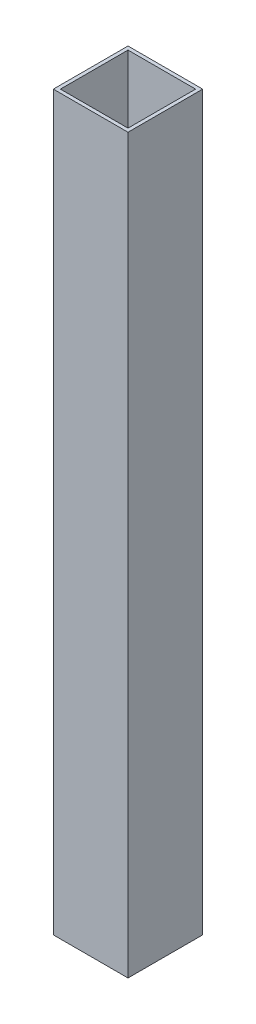
from build123d import *

# Parameters (mm, degrees)
SKETCH1_W           = 25.4
SKETCH1_H           = 25.4
SKETCH1_W_2         = 23
SKETCH1_H_2         = 23
BOSS_EXTRUDE1_DEPTH = 249.2


with BuildPart() as part:
    # Sketch1 → Boss-Extrude1 (new body)
    with BuildSketch(Plane(origin=(0, 0, 0), x_dir=(1, 0, 0), z_dir=(0, 1, 0))):
        with Locations((12.7, 12.7)):
            Rectangle(SKETCH1_W, SKETCH1_H)
        with Locations((12.7, 12.7)):
            Rectangle(SKETCH1_W_2, SKETCH1_H_2, mode=Mode.SUBTRACT)
    extrude(amount=BOSS_EXTRUDE1_DEPTH)


solid = part.part
